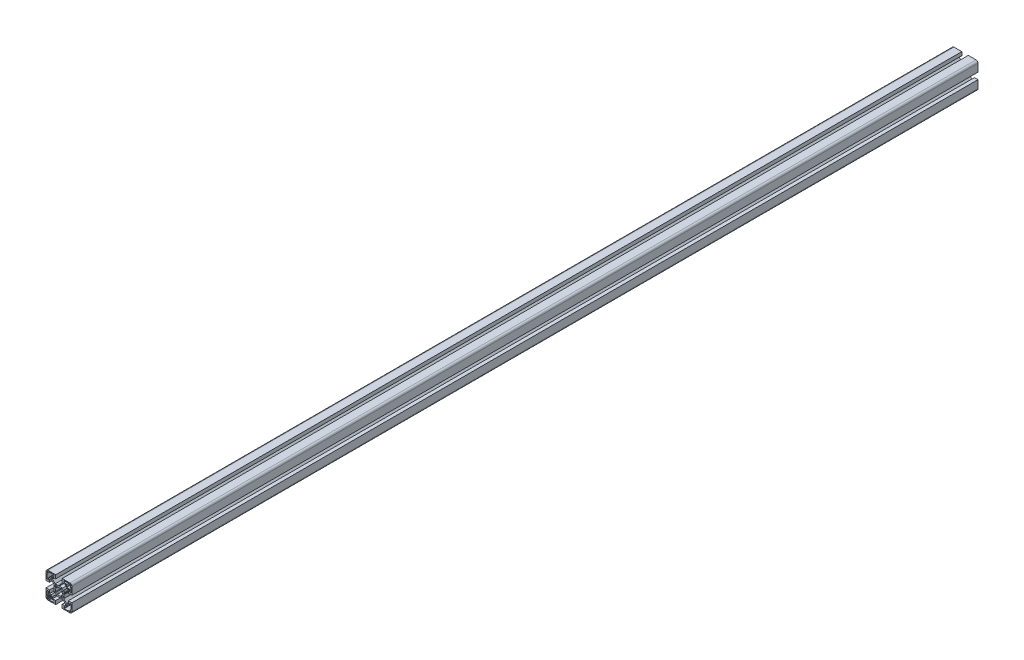
from build123d import *

# Parameters (mm, degrees)
BOSS_EXTRUDE1_DEPTH = 1400


with BuildPart() as part:
    # Sketch1 → Boss-Extrude1 (new body)
    with BuildSketch(Plane.XY):
        with BuildLine():
            Line((-11.767766953, -10), (-14.5, -10))
            Line((-14.5, -10), (-14.5, -5))
            Line((-14.5, -5), (-20, -5))
            Line((-20, -5), (-20, -17))
            ThreePointArc((-20, -17), (-19.121320344, -19.121320344), (-17, -20))
            Line((-17, -20), (-5, -20))
            Line((-5, -20), (-5, -14.5))
            Line((-5, -14.5), (-10, -14.5))
            Line((-10, -14.5), (-10, -11.767766953))
            Line((-10, -11.767766953), (-5.732233047, -7.5))
            Line((-5.732233047, -7.5), (-0.653589838, -7.5))
            ThreePointArc((-0.653589838, -7.5), (-0.524180316, -7.482962913), (-0.403589838, -7.433012702))
            Line((-0.403589838, -7.433012702), (0, -7.2))
            Line((0, -7.2), (0.403589838, -7.433012702))
            ThreePointArc((0.403589838, -7.433012702), (0.653589838, -7.5), (0.903589838, -7.433012702))
            Line((0.903589838, -7.433012702), (1.218885629, -7.250976592))
            Line((1.218885629, -7.250976592), (2.5, -7.5))
            Line((2.5, -7.5), (5.732233047, -7.5))
            Line((5.732233047, -7.5), (10, -11.767766953))
            Line((10, -11.767766953), (10, -14.5))
            Line((10, -14.5), (5, -14.5))
            Line((5, -14.5), (5, -20))
            Line((5, -20), (17, -20))
            ThreePointArc((17, -20), (19.121320344, -19.121320344), (20, -17))
            Line((20, -17), (20, -5))
            Line((20, -5), (14.5, -5))
            Line((14.5, -5), (14.5, -10))
            Line((14.5, -10), (11.767766953, -10))
            Line((11.767766953, -10), (7.5, -5.732233047))
            Line((7.5, -5.732233047), (7.5, -0.653589838))
            ThreePointArc((7.5, -0.653589838), (7.482962913, -0.524180316), (7.433012702, -0.403589838))
            Line((7.433012702, -0.403589838), (7.2, 0))
            Line((7.2, 0), (7.433012702, 0.403589838))
            ThreePointArc((7.433012702, 0.403589838), (7.5, 0.653589838), (7.433012702, 0.903589838))
            Line((7.433012702, 0.903589838), (7.250976592, 1.218885629))
            Line((7.250976592, 1.218885629), (7.5, 2.5))
            Line((7.5, 2.5), (7.5, 5.732233047))
            Line((7.5, 5.732233047), (11.767766953, 10))
            Line((11.767766953, 10), (14.5, 10))
            Line((14.5, 10), (14.5, 5))
            Line((14.5, 5), (20, 5))
            Line((20, 5), (20, 17))
            ThreePointArc((20, 17), (19.121320344, 19.121320344), (17, 20))
            Line((17, 20), (5, 20))
            Line((5, 20), (5, 14.5))
            Line((5, 14.5), (10, 14.5))
            Line((10, 14.5), (10, 11.767766953))
            Line((10, 11.767766953), (5.732233047, 7.5))
            Line((5.732233047, 7.5), (0.653589838, 7.5))
            ThreePointArc((0.653589838, 7.5), (0.524180316, 7.482962913), (0.403589838, 7.433012702))
            Line((0.403589838, 7.433012702), (0, 7.2))
            Line((0, 7.2), (-0.403589838, 7.433012702))
            ThreePointArc((-0.403589838, 7.433012702), (-0.653589838, 7.5), (-0.903589838, 7.433012702))
            Line((-0.903589838, 7.433012702), (-1.218885629, 7.250976592))
            Line((-1.218885629, 7.250976592), (-2.5, 7.5))
            Line((-2.5, 7.5), (-5.732233047, 7.5))
            Line((-5.732233047, 7.5), (-10, 11.767766953))
            Line((-10, 11.767766953), (-10, 14.5))
            Line((-10, 14.5), (-5, 14.5))
            Line((-5, 14.5), (-5, 20))
            Line((-5, 20), (-17, 20))
            ThreePointArc((-17, 20), (-19.121320344, 19.121320344), (-20, 17))
            Line((-20, 17), (-20, 5))
            Line((-20, 5), (-14.5, 5))
            Line((-14.5, 5), (-14.5, 10))
            Line((-14.5, 10), (-11.767766953, 10))
            Line((-11.767766953, 10), (-7.5, 5.732233047))
            Line((-7.5, 5.732233047), (-7.5, 0.653589838))
            ThreePointArc((-7.5, 0.653589838), (-7.482962913, 0.524180316), (-7.433012702, 0.403589838))
            Line((-7.433012702, 0.403589838), (-7.2, 0))
            Line((-7.2, 0), (-7.433012702, -0.403589838))
            ThreePointArc((-7.433012702, -0.403589838), (-7.5, -0.653589838), (-7.433012702, -0.903589838))
            Line((-7.433012702, -0.903589838), (-7.250976592, -1.218885629))
            Line((-7.250976592, -1.218885629), (-7.5, -2.5))
            Line((-7.5, -2.5), (-7.5, -5.732233047))
            Line((-7.5, -5.732233047), (-11.767766953, -10))
        make_face()
        with BuildLine():
            Line((7.5, 16.5), (7.5, 18.2))
            ThreePointArc((7.5, 18.2), (7.646446609, 18.553553391), (8, 18.7))
            Line((8, 18.7), (14.8, 18.7))
            ThreePointArc((14.8, 18.7), (14.941421356, 18.641421356), (15, 18.5))
            Line((15, 18.5), (15, 18.2))
            ThreePointArc((15, 18.2), (15.058578644, 18.058578644), (15.2, 18))
            Line((15.2, 18), (16.4, 18))
            ThreePointArc((16.4, 18), (16.541421356, 18.058578644), (16.6, 18.2))
            Line((16.6, 18.2), (16.6, 18.5))
            ThreePointArc((16.6, 18.5), (16.658578644, 18.641421356), (16.8, 18.7))
            Line((16.8, 18.7), (17.3, 18.7))
            ThreePointArc((17.3, 18.7), (17.512132034, 18.612132034), (17.6, 18.4))
            Line((17.6, 18.4), (17.6, 17.9))
            ThreePointArc((17.6, 17.9), (17.687867966, 17.687867966), (17.9, 17.6))
            Line((17.9, 17.6), (18.4, 17.6))
            ThreePointArc((18.4, 17.6), (18.612132034, 17.512132034), (18.7, 17.3))
            Line((18.7, 17.3), (18.7, 16.8))
            ThreePointArc((18.7, 16.8), (18.641421356, 16.658578644), (18.5, 16.6))
            Line((18.5, 16.6), (18.2, 16.6))
            ThreePointArc((18.2, 16.6), (18.058578644, 16.541421356), (18, 16.4))
            Line((18, 16.4), (18, 15.2))
            ThreePointArc((18, 15.2), (18.058578644, 15.058578644), (18.2, 15))
            Line((18.2, 15), (18.5, 15))
            ThreePointArc((18.5, 15), (18.641421356, 14.941421356), (18.7, 14.8))
            Line((18.7, 14.8), (18.7, 8))
            ThreePointArc((18.7, 8), (18.553553391, 7.646446609), (18.2, 7.5))
            Line((18.2, 7.5), (16.5, 7.5))
            ThreePointArc((16.5, 7.5), (16.146446609, 7.646446609), (16, 8))
            Line((16, 8), (16, 10.2))
            ThreePointArc((16, 10.2), (15.619238816, 11.119238816), (14.7, 11.5))
            Line((14.7, 11.5), (12, 11.5))
            ThreePointArc((12, 11.5), (11.646446609, 11.646446609), (11.5, 12))
            Line((11.5, 12), (11.5, 14.7))
            ThreePointArc((11.5, 14.7), (11.119238816, 15.619238816), (10.2, 16))
            Line((10.2, 16), (8, 16))
            ThreePointArc((8, 16), (7.646446609, 16.146446609), (7.5, 16.5))
        make_face(mode=Mode.SUBTRACT)
        with BuildLine():
            Line((14.8, -18.7), (8, -18.7))
            ThreePointArc((8, -18.7), (7.646446609, -18.553553391), (7.5, -18.2))
            Line((7.5, -18.2), (7.5, -16.5))
            ThreePointArc((7.5, -16.5), (7.646446609, -16.146446609), (8, -16))
            Line((8, -16), (10.2, -16))
            ThreePointArc((10.2, -16), (11.119238816, -15.619238816), (11.5, -14.7))
            Line((11.5, -14.7), (11.5, -12))
            ThreePointArc((11.5, -12), (11.646446609, -11.646446609), (12, -11.5))
            Line((12, -11.5), (14.7, -11.5))
            ThreePointArc((14.7, -11.5), (15.619238816, -11.119238816), (16, -10.2))
            Line((16, -10.2), (16, -8))
            ThreePointArc((16, -8), (16.146446609, -7.646446609), (16.5, -7.5))
            Line((16.5, -7.5), (18.2, -7.5))
            ThreePointArc((18.2, -7.5), (18.553553391, -7.646446609), (18.7, -8))
            Line((18.7, -8), (18.7, -14.8))
            ThreePointArc((18.7, -14.8), (18.641421356, -14.941421356), (18.5, -15))
            Line((18.5, -15), (18.2, -15))
            ThreePointArc((18.2, -15), (18.058578644, -15.058578644), (18, -15.2))
            Line((18, -15.2), (18, -16.4))
            ThreePointArc((18, -16.4), (18.058578644, -16.541421356), (18.2, -16.6))
            Line((18.2, -16.6), (18.5, -16.6))
            ThreePointArc((18.5, -16.6), (18.641421356, -16.658578644), (18.7, -16.8))
            Line((18.7, -16.8), (18.7, -17.3))
            ThreePointArc((18.7, -17.3), (18.612132034, -17.512132034), (18.4, -17.6))
            Line((18.4, -17.6), (17.9, -17.6))
            ThreePointArc((17.9, -17.6), (17.687867966, -17.687867966), (17.6, -17.9))
            Line((17.6, -17.9), (17.6, -18.4))
            ThreePointArc((17.6, -18.4), (17.512132034, -18.612132034), (17.3, -18.7))
            Line((17.3, -18.7), (16.8, -18.7))
            ThreePointArc((16.8, -18.7), (16.658578644, -18.641421356), (16.6, -18.5))
            Line((16.6, -18.5), (16.6, -18.2))
            ThreePointArc((16.6, -18.2), (16.541421356, -18.058578644), (16.4, -18))
            Line((16.4, -18), (15.2, -18))
            ThreePointArc((15.2, -18), (15.058578644, -18.058578644), (15, -18.2))
            Line((15, -18.2), (15, -18.5))
            ThreePointArc((15, -18.5), (14.941421356, -18.641421356), (14.8, -18.7))
        make_face(mode=Mode.SUBTRACT)
        with BuildLine():
            Line((-18.7, 16.8), (-18.7, 17.3))
            ThreePointArc((-18.7, 17.3), (-18.612132034, 17.512132034), (-18.4, 17.6))
            Line((-18.4, 17.6), (-17.9, 17.6))
            ThreePointArc((-17.9, 17.6), (-17.687867966, 17.687867966), (-17.6, 17.9))
            Line((-17.6, 17.9), (-17.6, 18.4))
            ThreePointArc((-17.6, 18.4), (-17.512132034, 18.612132034), (-17.3, 18.7))
            Line((-17.3, 18.7), (-16.8, 18.7))
            ThreePointArc((-16.8, 18.7), (-16.658578644, 18.641421356), (-16.6, 18.5))
            Line((-16.6, 18.5), (-16.6, 18.2))
            ThreePointArc((-16.6, 18.2), (-16.541421356, 18.058578644), (-16.4, 18))
            Line((-16.4, 18), (-15.2, 18))
            ThreePointArc((-15.2, 18), (-15.058578644, 18.058578644), (-15, 18.2))
            Line((-15, 18.2), (-15, 18.5))
            ThreePointArc((-15, 18.5), (-14.941421356, 18.641421356), (-14.8, 18.7))
            Line((-14.8, 18.7), (-8, 18.7))
            ThreePointArc((-8, 18.7), (-7.646446609, 18.553553391), (-7.5, 18.2))
            Line((-7.5, 18.2), (-7.5, 16.5))
            ThreePointArc((-7.5, 16.5), (-7.646446609, 16.146446609), (-8, 16))
            Line((-8, 16), (-10.2, 16))
            ThreePointArc((-10.2, 16), (-11.119238816, 15.619238816), (-11.5, 14.7))
            Line((-11.5, 14.7), (-11.5, 12))
            ThreePointArc((-11.5, 12), (-11.646446609, 11.646446609), (-12, 11.5))
            Line((-12, 11.5), (-14.7, 11.5))
            ThreePointArc((-14.7, 11.5), (-15.619238816, 11.119238816), (-16, 10.2))
            Line((-16, 10.2), (-16, 8))
            ThreePointArc((-16, 8), (-16.146446609, 7.646446609), (-16.5, 7.5))
            Line((-16.5, 7.5), (-18.2, 7.5))
            ThreePointArc((-18.2, 7.5), (-18.553553391, 7.646446609), (-18.7, 8))
            Line((-18.7, 8), (-18.7, 14.8))
            ThreePointArc((-18.7, 14.8), (-18.641421356, 14.941421356), (-18.5, 15))
            Line((-18.5, 15), (-18.2, 15))
            ThreePointArc((-18.2, 15), (-18.058578644, 15.058578644), (-18, 15.2))
            Line((-18, 15.2), (-18, 16.4))
            ThreePointArc((-18, 16.4), (-18.058578644, 16.541421356), (-18.2, 16.6))
            Line((-18.2, 16.6), (-18.5, 16.6))
            ThreePointArc((-18.5, 16.6), (-18.641421356, 16.658578644), (-18.7, 16.8))
        make_face(mode=Mode.SUBTRACT)
        with BuildLine():
            Line((-18.7, -14.8), (-18.7, -8))
            ThreePointArc((-18.7, -8), (-18.553553391, -7.646446609), (-18.2, -7.5))
            Line((-18.2, -7.5), (-16.5, -7.5))
            ThreePointArc((-16.5, -7.5), (-16.146446609, -7.646446609), (-16, -8))
            Line((-16, -8), (-16, -10.2))
            ThreePointArc((-16, -10.2), (-15.619238816, -11.119238816), (-14.7, -11.5))
            Line((-14.7, -11.5), (-12, -11.5))
            ThreePointArc((-12, -11.5), (-11.646446609, -11.646446609), (-11.5, -12))
            Line((-11.5, -12), (-11.5, -14.7))
            ThreePointArc((-11.5, -14.7), (-11.119238816, -15.619238816), (-10.2, -16))
            Line((-10.2, -16), (-8, -16))
            ThreePointArc((-8, -16), (-7.646446609, -16.146446609), (-7.5, -16.5))
            Line((-7.5, -16.5), (-7.5, -18.2))
            ThreePointArc((-7.5, -18.2), (-7.646446609, -18.553553391), (-8, -18.7))
            Line((-8, -18.7), (-14.8, -18.7))
            ThreePointArc((-14.8, -18.7), (-14.941421356, -18.641421356), (-15, -18.5))
            Line((-15, -18.5), (-15, -18.2))
            ThreePointArc((-15, -18.2), (-15.058578644, -18.058578644), (-15.2, -18))
            Line((-15.2, -18), (-16.4, -18))
            ThreePointArc((-16.4, -18), (-16.541421356, -18.058578644), (-16.6, -18.2))
            Line((-16.6, -18.2), (-16.6, -18.5))
            ThreePointArc((-16.6, -18.5), (-16.658578644, -18.641421356), (-16.8, -18.7))
            Line((-16.8, -18.7), (-17.3, -18.7))
            ThreePointArc((-17.3, -18.7), (-17.512132034, -18.612132034), (-17.6, -18.4))
            Line((-17.6, -18.4), (-17.6, -17.9))
            ThreePointArc((-17.6, -17.9), (-17.687867966, -17.687867966), (-17.9, -17.6))
            Line((-17.9, -17.6), (-18.4, -17.6))
            ThreePointArc((-18.4, -17.6), (-18.612132034, -17.512132034), (-18.7, -17.3))
            Line((-18.7, -17.3), (-18.7, -16.8))
            ThreePointArc((-18.7, -16.8), (-18.641421356, -16.658578644), (-18.5, -16.6))
            Line((-18.5, -16.6), (-18.2, -16.6))
            ThreePointArc((-18.2, -16.6), (-18.058578644, -16.541421356), (-18, -16.4))
            Line((-18, -16.4), (-18, -15.2))
            ThreePointArc((-18, -15.2), (-18.058578644, -15.058578644), (-18.2, -15))
            Line((-18.2, -15), (-18.5, -15))
            ThreePointArc((-18.5, -15), (-18.641421356, -14.941421356), (-18.7, -14.8))
        make_face(mode=Mode.SUBTRACT)
        with BuildLine():
            Line((-6, 3.490686899), (-6, 5))
            ThreePointArc((-6, 5), (-5.707106781, 5.707106781), (-5, 6))
            Line((-5, 6), (-3.490686899, 6))
            ThreePointArc((-3.490686899, 6), (-3.233167862, 5.92858365), (-3.049213103, 5.734735781))
            Line((-3.049213103, 5.734735781), (-2.689236216, 5.057717724))
            ThreePointArc((-2.689236216, 5.057717724), (-2.414618721, 4.821116073), (-2.052304818, 4.832240157))
            ThreePointArc((-2.052304818, 4.832240157), (0, 5.25), (2.052304818, 4.832240157))
            ThreePointArc((2.052304818, 4.832240157), (2.414618721, 4.821116073), (2.689236216, 5.057717724))
            Line((2.689236216, 5.057717724), (3.049213103, 5.734735781))
            ThreePointArc((3.049213103, 5.734735781), (3.233167862, 5.92858365), (3.490686899, 6))
            Line((3.490686899, 6), (5, 6))
            ThreePointArc((5, 6), (5.707106781, 5.707106781), (6, 5))
            Line((6, 5), (6, 3.490686899))
            ThreePointArc((6, 3.490686899), (5.92858365, 3.233167862), (5.734735781, 3.049213103))
            Line((5.734735781, 3.049213103), (5.057717724, 2.689236216))
            ThreePointArc((5.057717724, 2.689236216), (4.821116073, 2.414618721), (4.832240157, 2.052304818))
            ThreePointArc((4.832240157, 2.052304818), (5.25, 0), (4.832240157, -2.052304818))
            ThreePointArc((4.832240157, -2.052304818), (4.821116073, -2.414618721), (5.057717724, -2.689236216))
            Line((5.057717724, -2.689236216), (5.734735781, -3.049213103))
            ThreePointArc((5.734735781, -3.049213103), (5.92858365, -3.233167862), (6, -3.490686899))
            Line((6, -3.490686899), (6, -5))
            ThreePointArc((6, -5), (5.707106781, -5.707106781), (5, -6))
            Line((5, -6), (3.490686899, -6))
            ThreePointArc((3.490686899, -6), (3.233167862, -5.92858365), (3.049213103, -5.734735781))
            Line((3.049213103, -5.734735781), (2.689236216, -5.057717724))
            ThreePointArc((2.689236216, -5.057717724), (2.414618721, -4.821116073), (2.052304818, -4.832240157))
            ThreePointArc((2.052304818, -4.832240157), (0, -5.25), (-2.052304818, -4.832240157))
            ThreePointArc((-2.052304818, -4.832240157), (-2.414618721, -4.821116073), (-2.689236216, -5.057717724))
            Line((-2.689236216, -5.057717724), (-3.049213103, -5.734735781))
            ThreePointArc((-3.049213103, -5.734735781), (-3.233167862, -5.92858365), (-3.490686899, -6))
            Line((-3.490686899, -6), (-5, -6))
            ThreePointArc((-5, -6), (-5.707106781, -5.707106781), (-6, -5))
            Line((-6, -5), (-6, -3.490686899))
            ThreePointArc((-6, -3.490686899), (-5.92858365, -3.233167862), (-5.734735781, -3.049213103))
            Line((-5.734735781, -3.049213103), (-5.057717724, -2.689236216))
            ThreePointArc((-5.057717724, -2.689236216), (-4.821116073, -2.414618721), (-4.832240157, -2.052304818))
            ThreePointArc((-4.832240157, -2.052304818), (-5.25, 0), (-4.832240157, 2.052304818))
            ThreePointArc((-4.832240157, 2.052304818), (-4.821116073, 2.414618721), (-5.057717724, 2.689236216))
            Line((-5.057717724, 2.689236216), (-5.734735781, 3.049213103))
            ThreePointArc((-5.734735781, 3.049213103), (-5.92858365, 3.233167862), (-6, 3.490686899))
        make_face(mode=Mode.SUBTRACT)
    extrude(amount=-BOSS_EXTRUDE1_DEPTH)


solid = part.part
